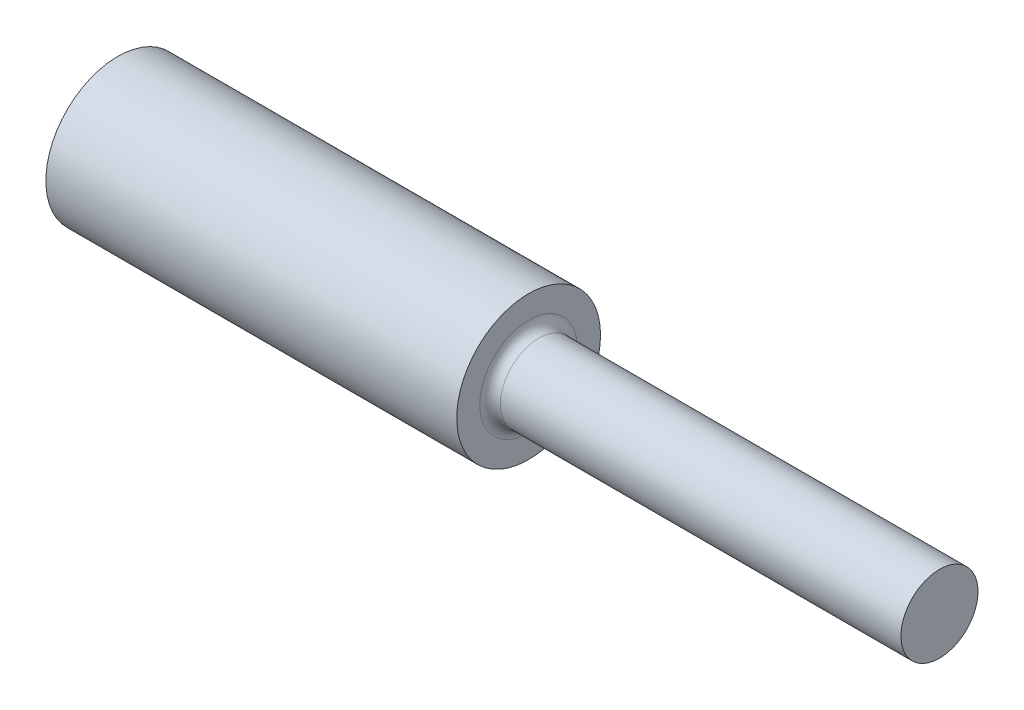
from build123d import *

# Parameters (mm, degrees)
FILLET2_R = 2.54


with BuildPart() as part:
    # Sketch3 → Revolve1 (revolve)
    with BuildSketch(Plane(origin=(0, 0, 0), x_dir=(-1, 0, 0), z_dir=(0, 0, -1))):
        Polygon((-101.6, 0), (-101.6, 9.525), (0, 9.525), (0, 17.78), (101.6, 17.78), (101.6, 0), align=None)
    revolve(axis=Axis((60.410810811, 0, 0), (-1, 0, 0)))

    # Fillet2
    fillet2_edges = [part.edges().sort_by_distance(p)[0] for p in [
        (0, -9.525, 0),
    ]]
    fillet(fillet2_edges, radius=FILLET2_R)


solid = part.part
